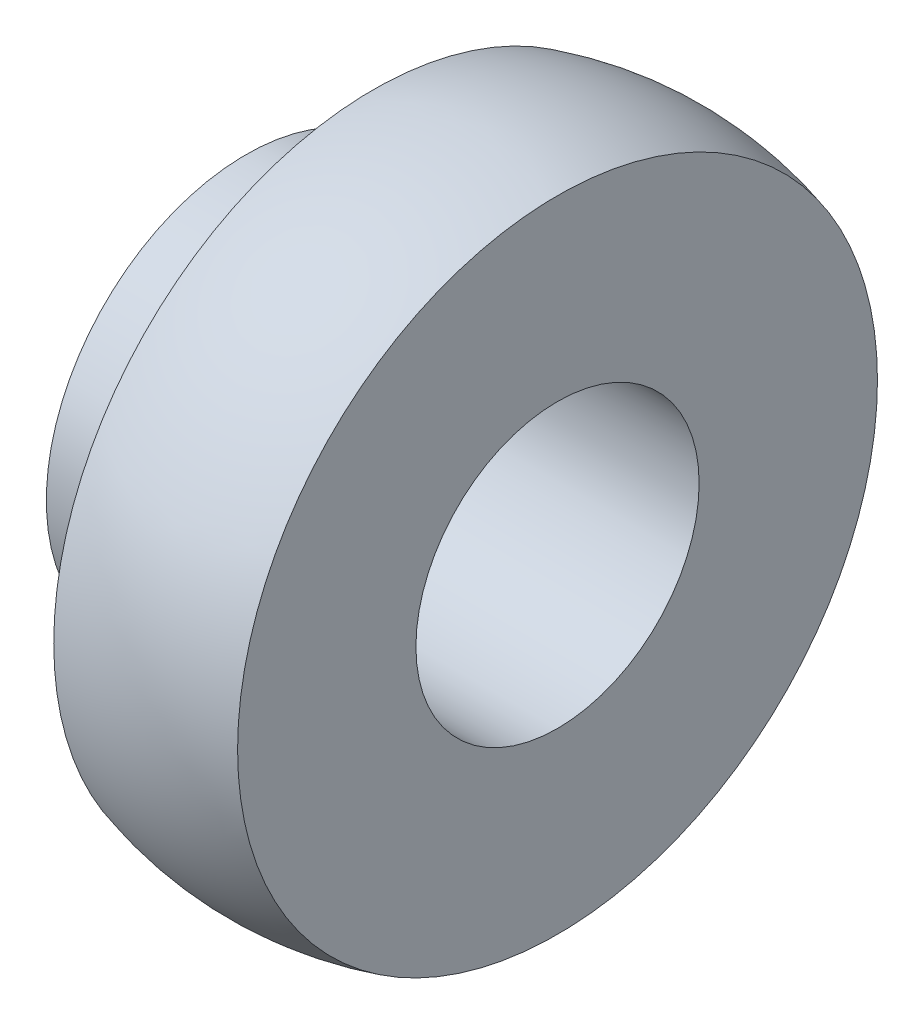
from build123d import *


with BuildPart() as part:
    # Szkic1 → Obrót2 (revolve)
    with BuildSketch(Plane(origin=(0, 0, 0), x_dir=(1, 0, 0), z_dir=(0, 1, 0))):
        with BuildLine():
            Line((6.467608229, -22.592477593), (6.467608229, -10))
            Line((6.467608229, -10), (-15.529312714, -10))
            Line((-15.529312714, -10), (-15.529312714, -14.1))
            Line((-15.529312714, -14.1), (-10.029312714, -14.1))
            Line((-10.029312714, -14.1), (-6.532391771, -14.1))
            Line((-6.532391771, -14.1), (-6.532391771, -22.57383126))
            ThreePointArc((-6.532391771, -22.57383126), (-0.033706799, -23.499975827), (6.467608229, -22.592477593))
        make_face()
    revolve(axis=Axis((6.470136678, 0, 0), (-1, 0, 0)))


solid = part.part
